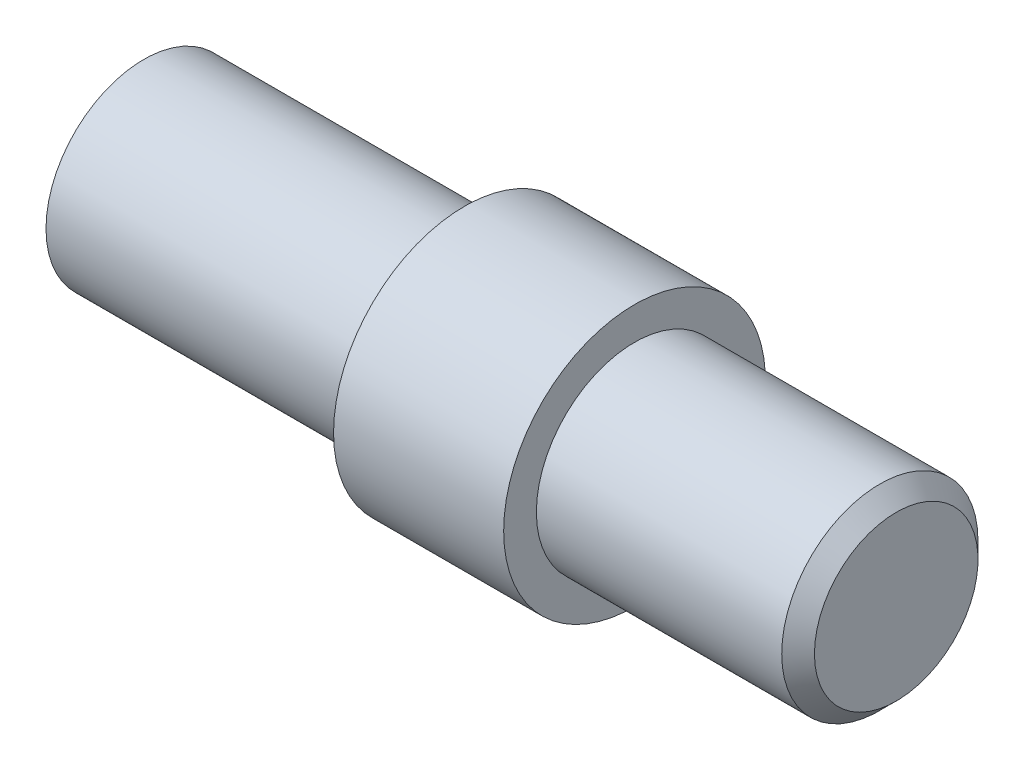
from build123d import *

# Parameters (mm, degrees)
CHAMFER1_SIZE                   = 0.5
TAP_DRILL_FOR_M3X0_5_TAP1_D     = 2.5
TAP_DRILL_FOR_M3X0_5_TAP1_DEPTH = 6
TAP_DRILL_FOR_M3X0_5_TAP1_TIP   = 0.751075774


with BuildPart() as part:
    # Sketch1 → Revolve1 (revolve)
    with BuildSketch(Plane.XY):
        Polygon((0, 0), (23, 0), (23, 3), (15, 3), (15, 4), (9.8, 4), (9.8, 2.99), (0, 2.99), align=None)
    revolve(axis=Axis((0, 0, 0), (1, 0, 0)))

    # Chamfer1
    chamfer1_edges = [part.edges().sort_by_distance(p)[0] for p in [
        (23, -3, 0),
    ]]
    chamfer(chamfer1_edges, length=CHAMFER1_SIZE)

    # Tap Drill for M3x0.5 Tap1
    with Locations(Plane.ZY):
        with Locations((0, 0)):
            Hole(TAP_DRILL_FOR_M3X0_5_TAP1_D / 2, depth=TAP_DRILL_FOR_M3X0_5_TAP1_DEPTH)
            with Locations((0, 0, -(TAP_DRILL_FOR_M3X0_5_TAP1_DEPTH + TAP_DRILL_FOR_M3X0_5_TAP1_TIP / 2))):  # 118° drill point
                Cone(0, TAP_DRILL_FOR_M3X0_5_TAP1_D / 2, TAP_DRILL_FOR_M3X0_5_TAP1_TIP, mode=Mode.SUBTRACT)


solid = part.part
